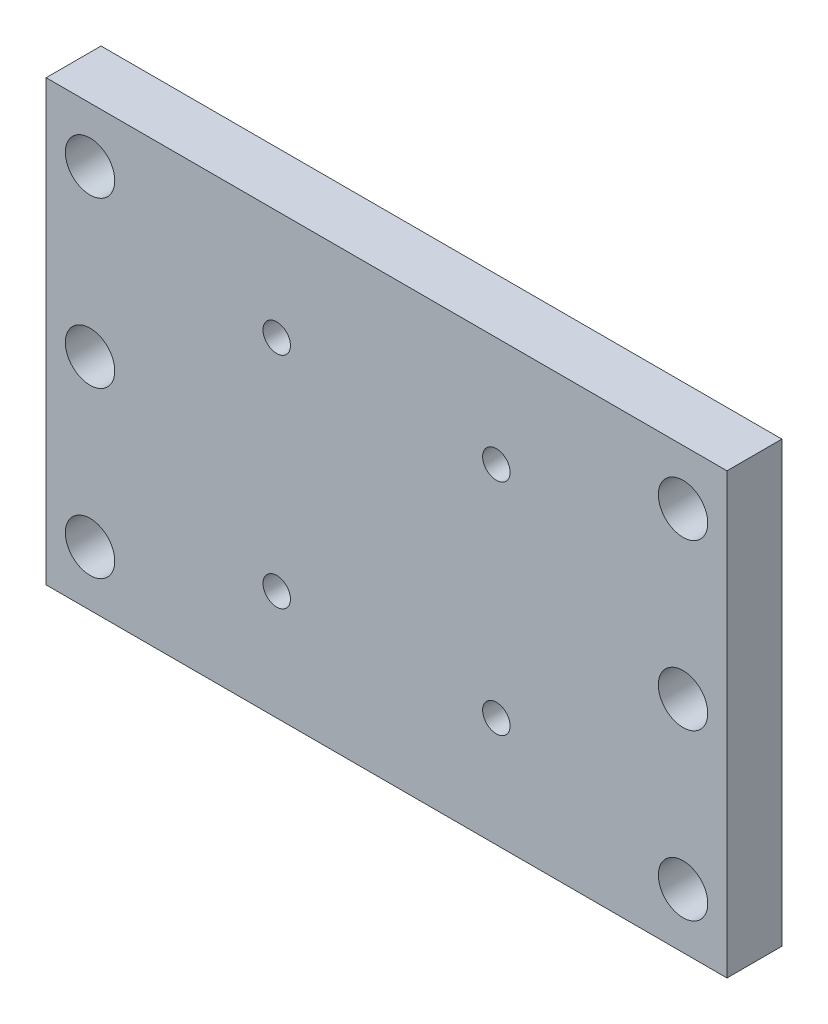
from build123d import *

# Parameters (mm, degrees)
SKIZZE1_W                       = 62
SKIZZE1_H                       = 40
SKIZZE1_R                       = 2.25
SKIZZE1_R_2                     = 1.25
AUFSATZ_LINEAR_AUSTRAGEN1_DEPTH = 5


with BuildPart() as part:
    # Skizze1 → Aufsatz-Linear austragen1 (new body)
    with BuildSketch(Plane.XY):
        with Locations((0, -4.599571734)):
            Rectangle(SKIZZE1_W, SKIZZE1_H)
        with Locations((-27, 10.400428266)):
            Circle(SKIZZE1_R, mode=Mode.SUBTRACT)
        with Locations((-27, -4.599571734)):
            Circle(SKIZZE1_R, mode=Mode.SUBTRACT)
        with Locations((-27, -19.599571734)):
            Circle(SKIZZE1_R, mode=Mode.SUBTRACT)
        with Locations((-10, 5.400428266)):
            Circle(SKIZZE1_R_2, mode=Mode.SUBTRACT)
        with Locations((-10, -14.599571734)):
            Circle(SKIZZE1_R_2, mode=Mode.SUBTRACT)
        with Locations((10, 5.400428266)):
            Circle(SKIZZE1_R_2, mode=Mode.SUBTRACT)
        with Locations((10, -14.599571734)):
            Circle(SKIZZE1_R_2, mode=Mode.SUBTRACT)
        with Locations((27, -19.599571734)):
            Circle(SKIZZE1_R, mode=Mode.SUBTRACT)
        with Locations((27, -4.599571734)):
            Circle(SKIZZE1_R, mode=Mode.SUBTRACT)
        with Locations((27, 10.400428266)):
            Circle(SKIZZE1_R, mode=Mode.SUBTRACT)
    extrude(amount=AUFSATZ_LINEAR_AUSTRAGEN1_DEPTH)


solid = part.part
